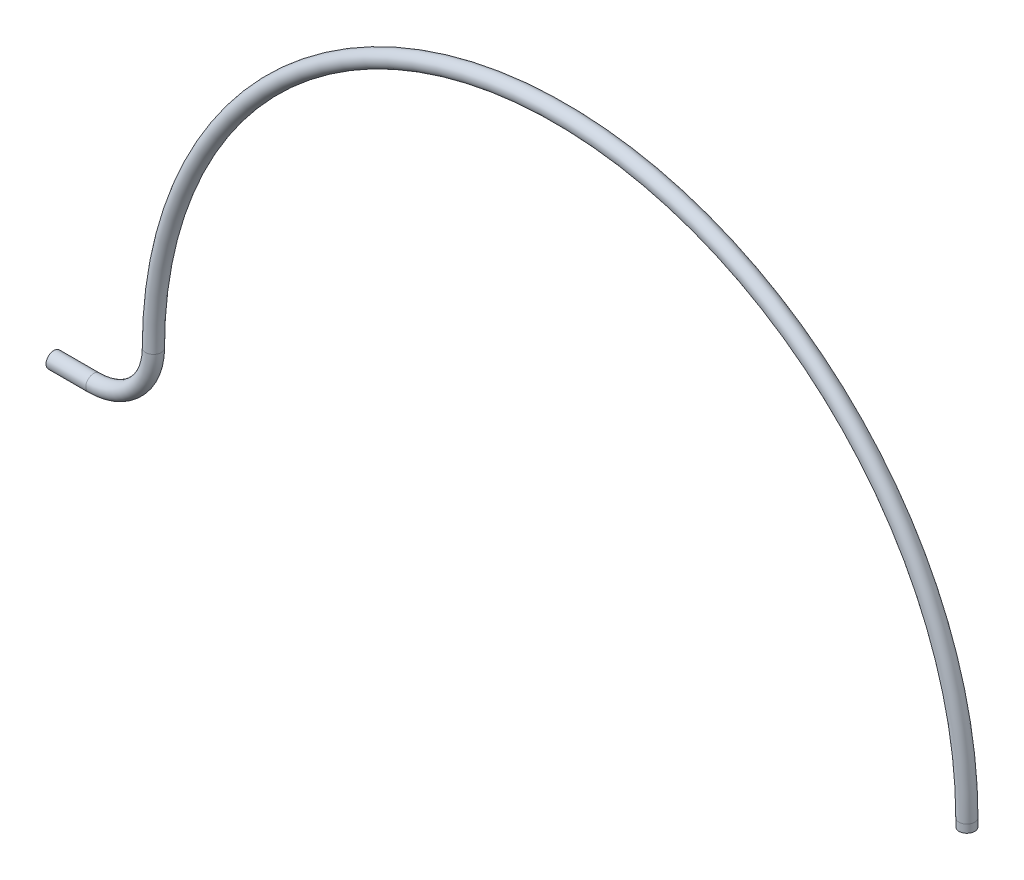
from build123d import *

# Parameters (mm, degrees)
SKETCH2_R   = 1.975
SKETCH2_R_2 = 0.95


with BuildPart() as part:
    # Sweep1: sweep along a path in Sketch1
    with BuildLine(Plane.XY) as sweep1_path:
        Line((-922.402789465, -43.105097392), (-912.402789465, -43.105097234))
        ThreePointArc((-912.402789465, -43.105097234), (-901.796152978, -38.711664118), (-897.402789465, -28.104998734))
        ThreePointArc((-897.402789465, -28.104998734), (-795.219537027, 74.079261821), (-693.03561251, -28.104326657))
        Line((-693.03561251, -28.104326657), (-693.03561251, -30.104326657))
    # Sketch2 → Sweep1 (sweep)
    with BuildSketch(Plane(origin=(-922.402789465, -43.105097392, 0), x_dir=(0, 0, -1), z_dir=(1, 1.6e-08, 0))):
        Circle(SKETCH2_R)
        Circle(SKETCH2_R_2, mode=Mode.SUBTRACT)
    sweep(path=sweep1_path.line)


solid = part.part
